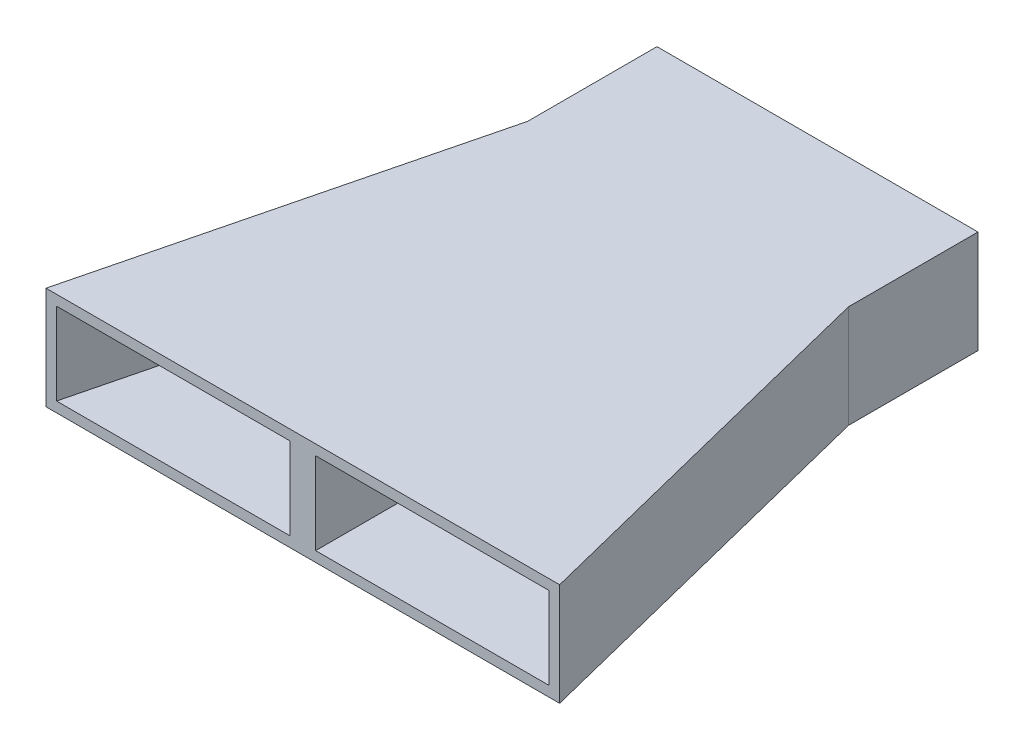
from build123d import *

# Parameters (mm, degrees)
EXTRUDE1_DEPTH = 5.08
SHELL1_T       = -0.508
EXTRUDE2_REACH = 6.572
SKETCH2_W      = 1.27
SKETCH2_H      = 25.4508


with BuildPart() as part:
    # Sketch1 → Extrude1 (new body)
    with BuildSketch(Plane(origin=(0, 0, 0), x_dir=(1, 0, 0), z_dir=(0, 1, 0))):
        Polygon((12.7, 0), (-12.7, 0), (-7.9375, 19.05), (-7.9375, 25.4508), (7.9375, 25.4508), (7.9375, 19.05), align=None)
    extrude(amount=EXTRUDE1_DEPTH)

    # Shell1
    shell1_openings = [part.faces().sort_by_distance(p)[0] for p in [
        (0, 2.54, -25.4508),
        (0, 2.54, 0),
    ]]
    offset(amount=SHELL1_T, openings=shell1_openings, kind=Kind.INTERSECTION)

    # Sketch2 → Extrude2 (add, up to next)
    with BuildSketch(Plane(origin=(0, 0.508, 0), x_dir=(-1, 0, 0), z_dir=(0, 1, 0)), mode=Mode.PRIVATE) as extrude2_sk1:
        with Locations((0, -12.7254)):
            Rectangle(SKETCH2_W, SKETCH2_H)
    extrude2_tool1 = extrude(extrude2_sk1.sketch, amount=EXTRUDE2_REACH, mode=Mode.PRIVATE) - part.part
    add(extrude2_tool1.solids().sort_by_distance((0, 0.508, -12.7254))[0])


solid = part.part
